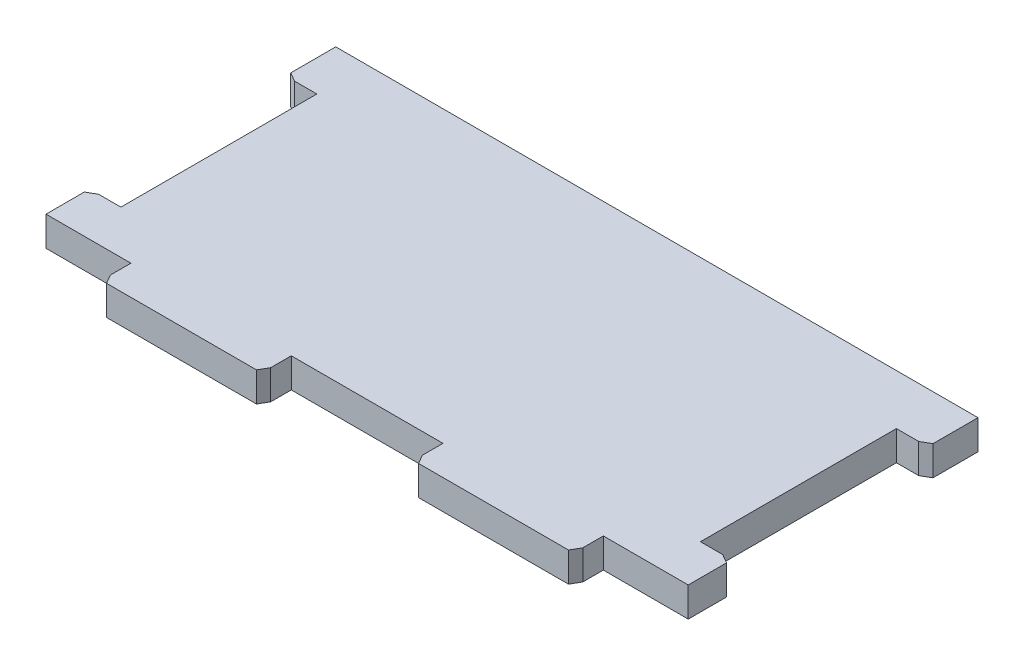
from build123d import *

# Parameters (mm, degrees)
SKETCH1_W             = 93.653112922
SKETCH1_H             = 50
BOSS_EXTRUDE1_DEPTH   = 4.318
SKETCH3_W             = 23.386037641
SKETCH3_H             = 4.318
BOSS_EXTRUDE2_DEPTH   = 4.318
CUT_EXTRUDE1_REACH    = 6.318
SKETCH4_W             = 4.572
SKETCH4_H             = 28.575
CUT_EXTRUDE2_REACH    = 6.318
SKETCH5_W             = 93.653112922
SKETCH5_H             = 7.747
SKETCH8_R             = 0.635
CUT_EXTRUDE4_DEPTH    = 0.127
CHAMFER1_SIZE         = 0.762
CHAMFER1_SIZE2        = 1.319822715
CHAMFER1_PART_2_SIZE  = 0.762
CHAMFER1_PART_2_SIZE2 = 1.319822715
CHAMFER1_PART_3_SIZE  = 0.762
CHAMFER1_PART_3_SIZE2 = 1.319822715
CHAMFER1_PART_4_SIZE  = 0.762
CHAMFER1_PART_4_SIZE2 = 1.319822715
CHAMFER2_SIZE         = 0.762
CHAMFER2_SIZE2        = 1.319822715
CHAMFER2_PART_2_SIZE  = 0.762
CHAMFER2_PART_2_SIZE2 = 1.319822715
CHAMFER2_PART_3_SIZE  = 0.762
CHAMFER2_PART_3_SIZE2 = 1.319822715
CHAMFER2_PART_4_SIZE  = 0.762
CHAMFER2_PART_4_SIZE2 = 1.319822715


with BuildPart() as part:
    # Sketch1 → Boss-Extrude1 (new body)
    with BuildSketch(Plane(origin=(0, 0, 0), x_dir=(1, 0, 0), z_dir=(0, 1, 0))):
        Rectangle(SKETCH1_W, SKETCH1_H)
    extrude(amount=BOSS_EXTRUDE1_DEPTH)

    # Sketch3 → Boss-Extrude2 (add)
    with BuildSketch(Plane.XZ):
        with Locations((-22.751037641, 27.159)):
            Rectangle(SKETCH3_W, SKETCH3_H)
        with Locations((22.751037641, 27.159)):
            Rectangle(SKETCH3_W, SKETCH3_H)
    extrude(amount=-BOSS_EXTRUDE2_DEPTH)

    # Sketch4 → Cut-Extrude1 (cut, up to next)
    with BuildSketch(Plane(origin=(0, 4.318, 0), x_dir=(1, 0, 0), z_dir=(0, 1, 0)), mode=Mode.PRIVATE) as cut_extrude1_sk1:
        with Locations((-44.540556461, -4.3625)):
            Rectangle(SKETCH4_W, SKETCH4_H)
    cut_extrude1_tool1 = extrude(cut_extrude1_sk1.sketch, amount=-CUT_EXTRUDE1_REACH, mode=Mode.PRIVATE) & part.part
    add(cut_extrude1_tool1.solids().sort_by_distance((-44.540556, 4.318, 4.3625))[0], mode=Mode.SUBTRACT)
    # Sketch4 → Cut-Extrude1 (cut, up to next)
    with BuildSketch(Plane(origin=(0, 4.318, 0), x_dir=(1, 0, 0), z_dir=(0, 1, 0)), mode=Mode.PRIVATE) as cut_extrude1_sk2:
        with Locations((44.540556461, -4.3625)):
            Rectangle(SKETCH4_W, SKETCH4_H)
    cut_extrude1_tool2 = extrude(cut_extrude1_sk2.sketch, amount=-CUT_EXTRUDE1_REACH, mode=Mode.PRIVATE) & part.part
    add(cut_extrude1_tool2.solids().sort_by_distance((44.540556, 4.318, 4.3625))[0], mode=Mode.SUBTRACT)

    # Sketch5 → Cut-Extrude2 (cut, up to next)
    with BuildSketch(Plane(origin=(0, 4.318, 0), x_dir=(1, 0, 0), z_dir=(0, 1, 0)), mode=Mode.PRIVATE) as cut_extrude2_sk1:
        with Locations((0, 21.1265)):
            Rectangle(SKETCH5_W, SKETCH5_H)
    cut_extrude2_tool1 = extrude(cut_extrude2_sk1.sketch, amount=-CUT_EXTRUDE2_REACH, mode=Mode.PRIVATE) & part.part
    add(cut_extrude2_tool1.solids().sort_by_distance((0, 4.318, -21.1265))[0], mode=Mode.SUBTRACT)

    # Sketch8 → Cut-Extrude4 (cut)
    with BuildSketch(Plane.XZ):
        with Locations((21.735037641, 26.778)):
            Circle(SKETCH8_R)
        with Locations((23.767037641, 26.778)):
            Circle(SKETCH8_R)
        with Locations((39.714556461, 6.3945)):
            Circle(SKETCH8_R)
        with Locations((39.714556461, 4.3625)):
            Circle(SKETCH8_R)
        with Locations((39.714556461, 2.3305)):
            Circle(SKETCH8_R)
        with Locations((-23.767037641, 26.778)):
            Circle(SKETCH8_R)
        with Locations((-21.735037641, 26.778)):
            Circle(SKETCH8_R)
        with Locations((-39.714556461, 5.3785)):
            Circle(SKETCH8_R)
        with Locations((-39.714556461, 3.3465)):
            Circle(SKETCH8_R)
    extrude(amount=-CUT_EXTRUDE4_DEPTH, mode=Mode.SUBTRACT)

    # Chamfer1
    chamfer1_edges = [part.edges().sort_by_distance(p)[0] for p in [
        (-34.444056461, 2.159, 29.318),
    ]]
    chamfer1_side = [part.faces().sort_by_distance(p)[0] for p in [
        (-22.751037641, 2.159, 29.318),
    ]]
    chamfer(chamfer1_edges, length=CHAMFER1_SIZE, length2=CHAMFER1_SIZE2, reference=chamfer1_side[0])

    # Chamfer1 part 2
    chamfer1_part_2_edges = [part.edges().sort_by_distance(p)[0] for p in [
        (11.05801882, 2.159, 29.318),
    ]]
    chamfer1_part_2_side = [part.faces().sort_by_distance(p)[0] for p in [
        (22.751037641, 2.159, 29.318),
    ]]
    chamfer(chamfer1_part_2_edges, length=CHAMFER1_PART_2_SIZE, length2=CHAMFER1_PART_2_SIZE2, reference=chamfer1_part_2_side[0])

    # Chamfer1 part 3
    chamfer1_part_3_edges = [part.edges().sort_by_distance(p)[0] for p in [
        (-46.826556461, 2.159, -9.925),
    ]]
    chamfer1_part_3_side = [part.faces().sort_by_distance(p)[0] for p in [
        (-46.826556461, 2.159, -13.589),
    ]]
    chamfer(chamfer1_part_3_edges, length=CHAMFER1_PART_3_SIZE, length2=CHAMFER1_PART_3_SIZE2, reference=chamfer1_part_3_side[0])

    # Chamfer1 part 4
    chamfer1_part_4_edges = [part.edges().sort_by_distance(p)[0] for p in [
        (46.826556461, 2.159, 18.65),
    ]]
    chamfer1_part_4_side = [part.faces().sort_by_distance(p)[0] for p in [
        (46.826556461, 2.159, 21.825),
    ]]
    chamfer(chamfer1_part_4_edges, length=CHAMFER1_PART_4_SIZE, length2=CHAMFER1_PART_4_SIZE2, reference=chamfer1_part_4_side[0])

    # Chamfer2
    chamfer2_edges = [part.edges().sort_by_distance(p)[0] for p in [
        (-11.05801882, 2.159, 29.318),
    ]]
    chamfer2_side = [part.faces().sort_by_distance(p)[0] for p in [
        (-22.370037641, 2.159, 29.318),
    ]]
    chamfer(chamfer2_edges, length=CHAMFER2_SIZE, length2=CHAMFER2_SIZE2, reference=chamfer2_side[0])

    # Chamfer2 part 2
    chamfer2_part_2_edges = [part.edges().sort_by_distance(p)[0] for p in [
        (34.444056461, 2.159, 29.318),
    ]]
    chamfer2_part_2_side = [part.faces().sort_by_distance(p)[0] for p in [
        (23.132037641, 2.159, 29.318),
    ]]
    chamfer(chamfer2_part_2_edges, length=CHAMFER2_PART_2_SIZE, length2=CHAMFER2_PART_2_SIZE2, reference=chamfer2_part_2_side[0])

    # Chamfer2 part 3
    chamfer2_part_3_edges = [part.edges().sort_by_distance(p)[0] for p in [
        (-46.826556461, 2.159, 18.65),
    ]]
    chamfer2_part_3_side = [part.faces().sort_by_distance(p)[0] for p in [
        (-46.826556461, 2.159, 21.825),
    ]]
    chamfer(chamfer2_part_3_edges, length=CHAMFER2_PART_3_SIZE, length2=CHAMFER2_PART_3_SIZE2, reference=chamfer2_part_3_side[0])

    # Chamfer2 part 4
    chamfer2_part_4_edges = [part.edges().sort_by_distance(p)[0] for p in [
        (46.826556461, 2.159, -9.925),
    ]]
    chamfer2_part_4_side = [part.faces().sort_by_distance(p)[0] for p in [
        (46.826556461, 2.159, -13.589),
    ]]
    chamfer(chamfer2_part_4_edges, length=CHAMFER2_PART_4_SIZE, length2=CHAMFER2_PART_4_SIZE2, reference=chamfer2_part_4_side[0])


solid = part.part
